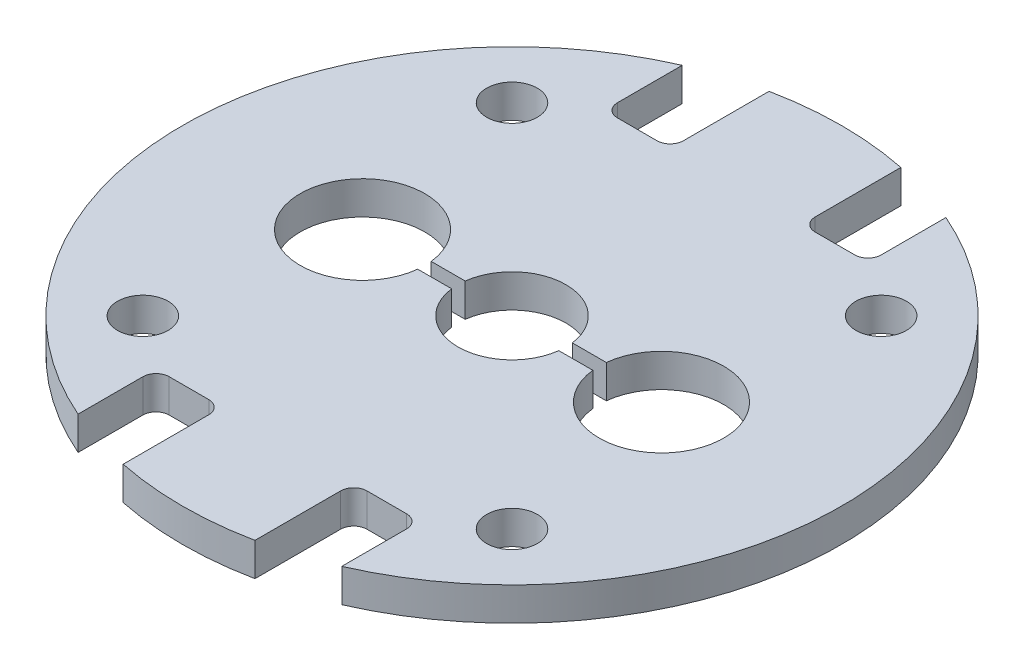
from build123d import *

# Parameters (mm, degrees)
BOSS_EXTRUDE1_DEPTH       = 0.8
CUT_EXTRUDE1_DEPTH        = 2.6
F_2_CLEARANCE_HOLE1_D     = 2.4384
F_2_CLEARANCE_HOLE1_DEPTH = 1.6


with BuildPart() as part:
    # Sketch1 → Boss-Extrude1 (new body, symmetric)
    with BuildSketch(Plane(origin=(0, 0, 0), x_dir=(1, 0, 0), z_dir=(0, 1, 0))):
        with BuildLine():
            Line((-6.35, 14.549677831), (-6.35, 11.43))
            ThreePointArc((-6.35, 11.43), (-6.164012806, 10.980987194), (-5.715, 10.795))
            Line((-5.715, 10.795), (-3.81, 10.795))
            ThreePointArc((-3.81, 10.795), (-3.360987194, 10.980987194), (-3.175, 11.43))
            Line((-3.175, 11.43), (-3.175, 15.554259867))
            ThreePointArc((-3.175, 15.554259867), (0, 15.875), (3.175, 15.554259867))
            Line((3.175, 15.554259867), (3.175, 11.43))
            ThreePointArc((3.175, 11.43), (3.360987194, 10.980987194), (3.81, 10.795))
            Line((3.81, 10.795), (5.715, 10.795))
            ThreePointArc((5.715, 10.795), (6.164012806, 10.980987194), (6.35, 11.43))
            Line((6.35, 11.43), (6.35, 14.549677831))
            ThreePointArc((6.35, 14.549677831), (15.875, 0), (6.35, -14.549677831))
            Line((6.35, -14.549677831), (6.35, -11.43))
            ThreePointArc((6.35, -11.43), (6.164012806, -10.980987194), (5.715, -10.795))
            Line((5.715, -10.795), (3.81, -10.795))
            ThreePointArc((3.81, -10.795), (3.360987194, -10.980987194), (3.175, -11.43))
            Line((3.175, -11.43), (3.175, -15.554259867))
            ThreePointArc((3.175, -15.554259867), (0, -15.875), (-3.175, -15.554259867))
            Line((-3.175, -15.554259867), (-3.175, -11.43))
            ThreePointArc((-3.175, -11.43), (-3.360987194, -10.980987194), (-3.81, -10.795))
            Line((-3.81, -10.795), (-5.715, -10.795))
            ThreePointArc((-5.715, -10.795), (-6.164012806, -10.980987194), (-6.35, -11.43))
            Line((-6.35, -11.43), (-6.35, -14.549677831))
            ThreePointArc((-6.35, -14.549677831), (-15.875, 0), (-6.35, 14.549677831))
        make_face()
    extrude(amount=BOSS_EXTRUDE1_DEPTH, both=True)

    # Sketch2 → Cut-Extrude1 (cut, through all)
    with BuildSketch(Plane(origin=(0, 0.8, 0), x_dir=(1, 0, 0), z_dir=(0, 1, 0))):
        with BuildLine():
            Line((-4.217656123, 0.325), (-2.579607528, 0.325))
            ThreePointArc((-2.579607528, 0.325), (0, 2.6), (2.579607528, 0.325))
            Line((2.579607528, 0.325), (4.217656123, 0.325))
            ThreePointArc((4.217656123, 0.325), (10.2, 0), (4.217656123, -0.325))
            Line((4.217656123, -0.325), (2.579607528, -0.325))
            ThreePointArc((2.579607528, -0.325), (0, -2.6), (-2.579607528, -0.325))
            Line((-2.579607528, -0.325), (-4.217656123, -0.325))
            ThreePointArc((-4.217656123, -0.325), (-10.2, 0), (-4.217656123, 0.325))
        make_face()
    extrude(amount=-CUT_EXTRUDE1_DEPTH, mode=Mode.SUBTRACT)

    # #2 Clearance Hole1
    with Locations(Plane(origin=(0, 0.8, 0), x_dir=(1, 0, 0), z_dir=(0, 1, 0))):
        with Locations((-8.89, 8.89), (8.89, 8.89), (-8.89, -8.89), (8.89, -8.89)):
            Hole(F_2_CLEARANCE_HOLE1_D / 2, depth=F_2_CLEARANCE_HOLE1_DEPTH)


solid = part.part
